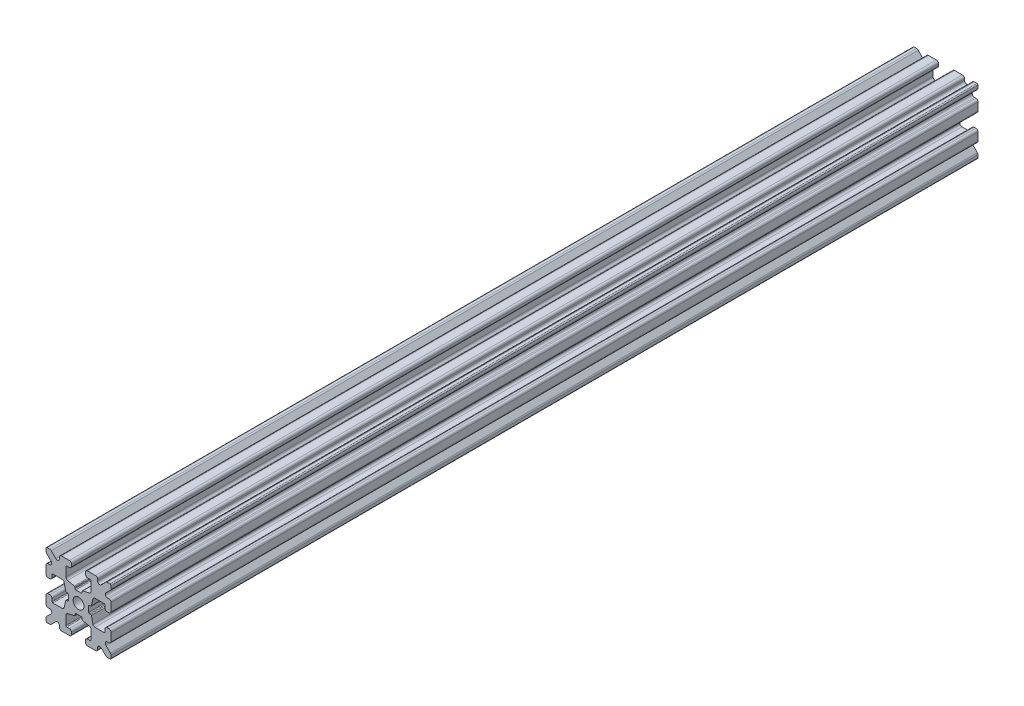
from build123d import *

# Parameters (mm, degrees)
SKETCH1_W           = 15
SKETCH1_H           = 15
SKETCH1_R           = 1.25
BOSS_EXTRUDE1_DEPTH = 100
FILLET1_R           = 0.25
CUT_EXTRUDE1_DEPTH  = 201
CUT_EXTRUDE3_DEPTH  = 201
FILLET3_R           = 0.5
FILLET4_R           = 0.5
FILLET5_R           = 3
FILLET6_R           = 0.2
CUT_EXTRUDE4_DEPTH  = 201
FILLET8_R           = 0.5
SKETCH6_W           = 5.1529354
SKETCH6_H           = 1.651
SKETCH6_W_2         = 1.651
SKETCH6_H_2         = 5.1529354
CUT_EXTRUDE5_DEPTH  = 201
FILLET10_R          = 0.2


with BuildPart() as part:
    # Sketch1 → Boss-Extrude1 (new body, symmetric)
    with BuildSketch(Plane.XY):
        Rectangle(SKETCH1_W, SKETCH1_H)
        Circle(SKETCH1_R, mode=Mode.SUBTRACT)
    extrude(amount=BOSS_EXTRUDE1_DEPTH, both=True)

    # Fillet1
    fillet1_edges = [part.edges().sort_by_distance(p)[0] for p in [
        (7.5, -7.5, 0),
        (-7.5, -7.5, 0),
        (-7.5, 7.5, 0),
        (7.5, 7.5, 0),
    ]]
    fillet(fillet1_edges, radius=FILLET1_R)

    # Sketch2 → Cut-Extrude1 (cut, through all)
    with BuildSketch(Plane.XY.offset(100)):
        Polygon((-7.5, 1.6), (-6.1, 1.6), (-6.1, 2.9), (-3.4, 2.9), (-3.4, -2.9), (-6.1, -2.9), (-6.1, -1.6), (-7.5, -1.6), align=None)
        Polygon((2.9, 6.1), (1.6, 6.1), (1.6, 7.5), (-1.6, 7.5), (-1.6, 6.1), (-2.9, 6.1), (-2.9, 3.4), (2.9, 3.4), align=None)
        Polygon((-1.6, -7.5), (-1.6, -6.1), (-2.9, -6.1), (-2.9, -3.4), (2.9, -3.4), (2.9, -6.1), (1.6, -6.1), (1.6, -7.5), align=None)
        Polygon((6.1, -2.9), (6.1, -1.6), (7.5, -1.6), (7.5, 1.6), (6.1, 1.6), (6.1, 2.9), (3.4, 2.9), (3.4, -2.9), align=None)
    extrude(amount=-CUT_EXTRUDE1_DEPTH, mode=Mode.SUBTRACT)

    # Sketch4 → Cut-Extrude3 (cut, through all)
    with BuildSketch(Plane.XY.offset(100)):
        Polygon((-3.4, 2.9), (-2.75, 0), (-3.4, -2.9), align=None)
        Polygon((-2.9, 3.4), (0, 2.75), (2.9, 3.4), align=None)
        Polygon((3.4, 2.9), (2.75, 0), (3.4, -2.9), align=None)
        Polygon((-2.9, -3.4), (0, -2.75), (2.9, -3.4), align=None)
    extrude(amount=-CUT_EXTRUDE3_DEPTH, mode=Mode.SUBTRACT)

    # Fillet3
    fillet3_edges = [part.edges().sort_by_distance(p)[0] for p in [
        (1.6, -7.5, 0),
        (-1.6, -7.5, 0),
        (-1.6, -6.1, 0),
        (1.6, -6.1, 0),
        (6.1, 1.6, 0),
        (7.5, 1.6, 0),
        (7.5, -1.6, 0),
        (6.1, -1.6, 0),
        (-7.5, -1.6, 0),
        (-7.5, 1.6, 0),
        (-6.1, 1.6, 0),
        (-6.1, -1.6, 0),
        (-1.6, 6.1, 0),
        (-1.6, 7.5, 0),
        (1.6, 7.5, 0),
        (1.6, 6.1, 0),
    ]]
    fillet(fillet3_edges, radius=FILLET3_R)

    # Fillet4
    fillet4_edges = [part.edges().sort_by_distance(p)[0] for p in [
        (-2.9, -3.4, 0),
        (2.9, -3.4, 0),
        (3.4, -2.9, 0),
        (3.4, 2.9, 0),
        (-3.4, 2.9, 0),
        (-3.4, -2.9, 0),
        (2.9, 3.4, 0),
        (-2.9, 3.4, 0),
    ]]
    fillet(fillet4_edges, radius=FILLET4_R)

    # Fillet5
    fillet5_edges = [part.edges().sort_by_distance(p)[0] for p in [
        (-2.75, 0, 0),
        (0, 2.75, 0),
        (2.75, 0, 0),
        (0, -2.75, 0),
    ]]
    fillet(fillet5_edges, radius=FILLET5_R)

    # Fillet6
    fillet6_edges = [part.edges().sort_by_distance(p)[0] for p in [
        (-2.9, -6.1, 0),
        (2.9, -6.1, 0),
        (6.1, -2.9, 0),
        (6.1, 2.9, 0),
        (-6.1, 2.9, 0),
        (-6.1, -2.9, 0),
        (2.9, 6.1, 0),
        (-2.9, 6.1, 0),
    ]]
    fillet(fillet6_edges, radius=FILLET6_R)

    # Sketch5 → Cut-Extrude4 (cut, through all)
    with BuildSketch(Plane.XY.offset(100)):
        Polygon((-7.5, 6.439339828), (-5.460660172, 4.4), (-7.5, 4.4), align=None)
        Polygon((-6.439339828, 7.5), (-4.4, 5.460660172), (-4.4, 7.5), align=None)
        Polygon((4.4, 7.5), (6.439339828, 7.5), (4.4, 5.460660172), align=None)
        Polygon((7.5, 6.439339828), (7.5, 4.4), (5.460660172, 4.4), align=None)
        Polygon((7.5, -6.439339828), (5.460660172, -4.4), (7.5, -4.4), align=None)
        Polygon((6.439339828, -7.5), (4.4, -5.460660172), (4.4, -7.5), align=None)
        Polygon((-4.4, -7.5), (-6.439339828, -7.5), (-4.4, -5.460660172), align=None)
        Polygon((-7.5, -6.439339828), (-7.5, -4.4), (-5.460660172, -4.4), align=None)
    extrude(amount=-CUT_EXTRUDE4_DEPTH, mode=Mode.SUBTRACT)

    # Fillet8
    fillet8_edges = [part.edges().sort_by_distance(p)[0] for p in [
        (-7.5, 4.4, 0),
        (-7.5, 6.439339828, 0),
        (-5.460660172, 4.4, 0),
        (7.5, -4.4, 0),
        (7.5, -6.439339828, 0),
        (5.460660172, -4.4, 0),
        (5.460660172, 4.4, 0),
        (7.5, 6.439339828, 0),
        (7.5, 4.4, 0),
        (-4.4, 7.5, 0),
        (-4.4, 5.460660172, 0),
        (-6.439339828, 7.5, 0),
        (-5.460660172, -4.4, 0),
        (-7.5, -6.439339828, 0),
        (-7.5, -4.4, 0),
        (4.4, 5.460660172, 0),
        (4.4, 7.5, 0),
        (6.439339828, 7.5, 0),
        (6.439339828, -7.5, 0),
        (4.4, -7.5, 0),
        (4.4, -5.460660172, 0),
        (-6.439339828, -7.5, 0),
        (-4.4, -5.460660172, 0),
        (-4.4, -7.5, 0),
    ]]
    fillet(fillet8_edges, radius=FILLET8_R)

    # Sketch6 → Cut-Extrude5 (cut, through all)
    with BuildSketch(Plane.XY.offset(100)):
        with Locations((4.9235323, 0)):
            Rectangle(SKETCH6_W, SKETCH6_H)
        with Locations((0, -4.9235323)):
            Rectangle(SKETCH6_W_2, SKETCH6_H_2)
        with Locations((-4.9235323, 0)):
            Rectangle(SKETCH6_W, SKETCH6_H)
        with Locations((0, 4.9235323)):
            Rectangle(SKETCH6_W_2, SKETCH6_H_2)
    extrude(amount=-CUT_EXTRUDE5_DEPTH, mode=Mode.SUBTRACT)

    # Fillet10
    fillet10_edges = [part.edges().sort_by_distance(p)[0] for p in [
        (0.8255, -2.935025862, 0),
        (-0.8255, -2.935025862, 0),
        (0.8255, -2.3470646, 0),
        (-0.8255, -2.3470646, 0),
        (2.935025862, 0.8255, 0),
        (2.935025862, -0.8255, 0),
        (2.3470646, 0.8255, 0),
        (2.3470646, -0.8255, 0),
        (-2.935025862, -0.8255, 0),
        (-2.935025862, 0.8255, 0),
        (-2.3470646, -0.8255, 0),
        (-2.3470646, 0.8255, 0),
        (-0.8255, 2.935025862, 0),
        (0.8255, 2.935025862, 0),
        (-0.8255, 2.3470646, 0),
        (0.8255, 2.3470646, 0),
    ]]
    fillet(fillet10_edges, radius=FILLET10_R)


solid = part.part
